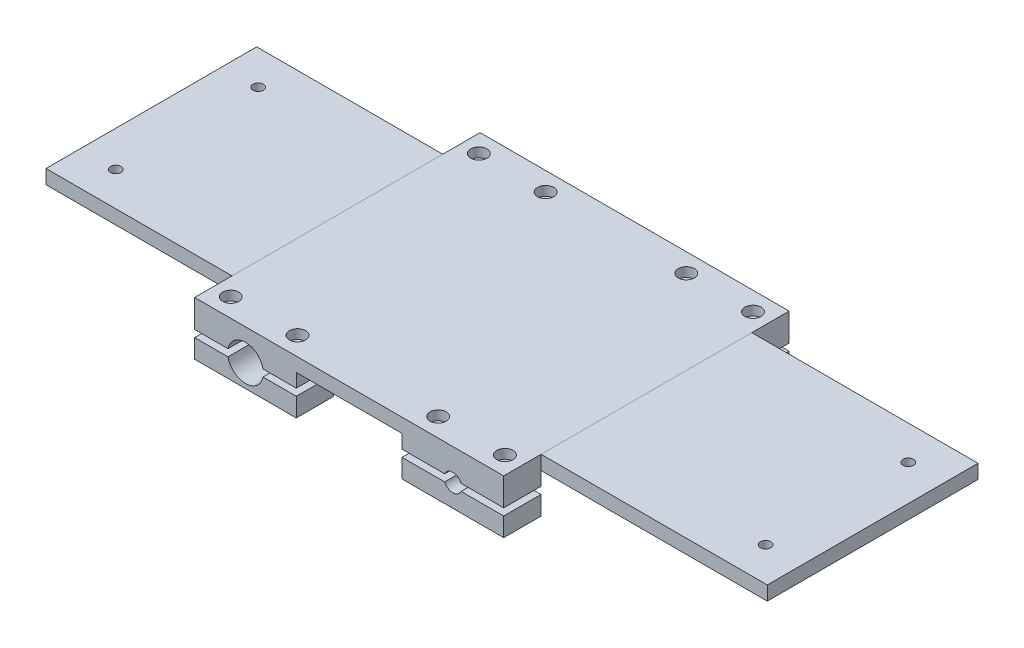
from build123d import *

# Parameters (mm, degrees)
SKETCH1_W           = 220
SKETCH1_H           = 31.75
SKETCH1_R           = 12.7
SKETCH1_R_2         = 6.35
BOSS_EXTRUDE1_DEPTH = 203.2
SKETCH3_W           = 220
SKETCH3_H           = 6.35
BOSS_EXTRUDE2_DEPTH = 203.2
SKETCH4_W           = 150
SKETCH4_H           = 28.1
CUT_EXTRUDE1_DEPTH  = 253.2
SKETCH5_W           = 75.275
SKETCH5_H           = 28.1
CUT_EXTRUDE2_DEPTH  = 203.2
SKETCH6_R           = 3.7258
CUT_EXTRUDE3_DEPTH  = 203.2
SKETCH7_W           = 220
SKETCH7_H           = 5
CUT_EXTRUDE4_DEPTH  = 203.2
SKETCH8_W           = 150
SKETCH8_H           = 10
BOSS_EXTRUDE3_DEPTH = 132.41370821
SKETCH9_W           = 150
SKETCH9_H           = 10
BOSS_EXTRUDE4_DEPTH = 161.04729179
SKETCH10_R          = 3.7258
CUT_EXTRUDE5_DEPTH  = 10
SKETCH11_R          = 5.7625
CUT_EXTRUDE6_DEPTH  = 6.6675


with BuildPart() as part:
    # Sketch1 → Boss-Extrude1 (new body)
    with BuildSketch(Plane.XY):
        Rectangle(SKETCH1_W, SKETCH1_H)
        with Locations((-73.81875, 0)):
            Circle(SKETCH1_R, mode=Mode.SUBTRACT)
        with Locations((73.81875, 0)):
            Circle(SKETCH1_R_2, mode=Mode.SUBTRACT)
    extrude(amount=BOSS_EXTRUDE1_DEPTH)

    # Sketch3 → Boss-Extrude2 (add)
    with BuildSketch(Plane.XY.offset(203.2)):
        with Locations((0, 19.05)):
            Rectangle(SKETCH3_W, SKETCH3_H)
    extrude(amount=-BOSS_EXTRUDE2_DEPTH)

    # Sketch4 → Cut-Extrude1 (cut)
    with BuildSketch(Plane.ZY.offset(110)):
        with Locations((101.6, -1.825)):
            Rectangle(SKETCH4_W, SKETCH4_H)
    extrude(amount=-CUT_EXTRUDE1_DEPTH, mode=Mode.SUBTRACT)

    # Sketch5 → Cut-Extrude2 (cut)
    with BuildSketch(Plane(origin=(0, 0, 0), x_dir=(-1, 0, 0), z_dir=(0, 0, -1))):
        with Locations((0, -1.825)):
            Rectangle(SKETCH5_W, SKETCH5_H)
    extrude(amount=-CUT_EXTRUDE2_DEPTH, mode=Mode.SUBTRACT)

    # Sketch6 → Cut-Extrude3 (cut)
    with BuildSketch(Plane.XZ.offset(15.875)):
        with Locations((-50.06875, 189.9)):
            Circle(SKETCH6_R)
        with Locations((-97.56875, 189.9)):
            Circle(SKETCH6_R)
        with Locations((-97.56875, 13.3)):
            Circle(SKETCH6_R)
        with Locations((-50.06875, 13.3)):
            Circle(SKETCH6_R)
        with Locations((50.06875, 13.3)):
            Circle(SKETCH6_R)
        with Locations((97.56875, 13.3)):
            Circle(SKETCH6_R)
        with Locations((97.56875, 189.9)):
            Circle(SKETCH6_R)
        with Locations((50.06875, 189.9)):
            Circle(SKETCH6_R)
    extrude(amount=-CUT_EXTRUDE3_DEPTH, mode=Mode.SUBTRACT)

    # Sketch7 → Cut-Extrude4 (cut)
    with BuildSketch(Plane(origin=(0, 0, 0), x_dir=(-1, 0, 0), z_dir=(0, 0, -1))):
        Rectangle(SKETCH7_W, SKETCH7_H)
    extrude(amount=-CUT_EXTRUDE4_DEPTH, mode=Mode.SUBTRACT)

    # Sketch8 → Boss-Extrude3 (add)
    with BuildSketch(Plane.ZY.offset(110)):
        with Locations((101.6, 17.225)):
            Rectangle(SKETCH8_W, SKETCH8_H)
    extrude(amount=BOSS_EXTRUDE3_DEPTH)

    # Sketch9 → Boss-Extrude4 (add)
    with BuildSketch(Plane(origin=(110, 0, 0), x_dir=(0, 0, -1), z_dir=(1, 0, 0))):
        with Locations((-101.6, 17.225)):
            Rectangle(SKETCH9_W, SKETCH9_H)
    extrude(amount=BOSS_EXTRUDE4_DEPTH)

    # Sketch10 → Cut-Extrude5 (cut)
    with BuildSketch(Plane(origin=(0, 22.225, 0), x_dir=(1, 0, 0), z_dir=(0, 1, 0))):
        with Locations((-217.013708212, -152.4)):
            Circle(SKETCH10_R)
        with Locations((-217.013708212, -50.966658535)):
            Circle(SKETCH10_R)
        with Locations((245.647291788, -50.8)):
            Circle(SKETCH10_R)
        with Locations((245.647291788, -152.4)):
            Circle(SKETCH10_R)
    extrude(amount=-CUT_EXTRUDE5_DEPTH, mode=Mode.SUBTRACT)

    # Sketch11 → Cut-Extrude6 (cut)
    with BuildSketch(Plane(origin=(0, 22.225, 0), x_dir=(1, 0, 0), z_dir=(0, 1, 0))):
        with Locations((97.56875, -13.3)):
            Circle(SKETCH11_R)
        with Locations((50.06875, -13.3)):
            Circle(SKETCH11_R)
        with Locations((97.56875, -189.9)):
            Circle(SKETCH11_R)
        with Locations((50.06875, -189.9)):
            Circle(SKETCH11_R)
        with Locations((-50.06875, -189.9)):
            Circle(SKETCH11_R)
        with Locations((-97.56875, -189.9)):
            Circle(SKETCH11_R)
        with Locations((-97.56875, -13.3)):
            Circle(SKETCH11_R)
        with Locations((-50.06875, -13.3)):
            Circle(SKETCH11_R)
    extrude(amount=-CUT_EXTRUDE6_DEPTH, mode=Mode.SUBTRACT)


solid = part.part
